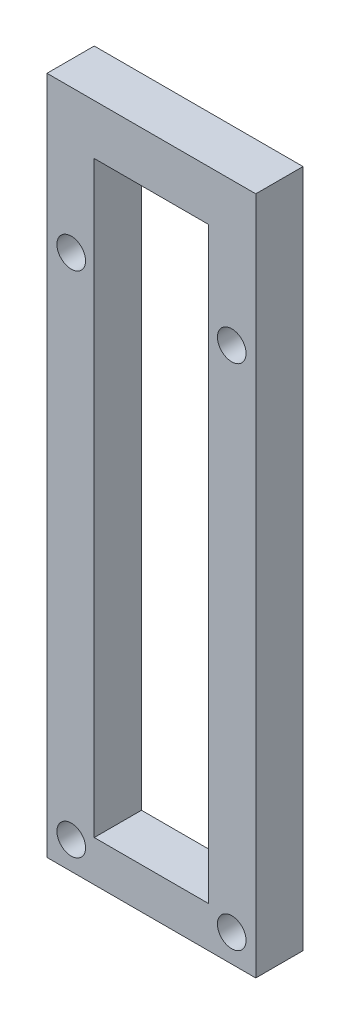
from build123d import *

# Parameters (mm, degrees)
BOSS_EXTRUDE1_DEPTH = 6.6
BOSS_EXTRUDE2_REACH = 24.56
SKETCH3_W           = 6.6
SKETCH3_H           = 7.003924561
SKETCH4_R           = 2
CUT_EXTRUDE1_DEPTH  = 15
SKETCH5_R           = 2
BOSS_EXTRUDE3_DEPTH = 6.69


with BuildPart() as part:
    # Sketch2 → Boss-Extrude1 (new body)
    with BuildSketch(Plane.XY):
        Polygon((0, 0), (0, 94.86), (-6.6, 94.86), (-6.6, 5.71), (-22.56, 5.71), (-22.56, 94.86), (-29.16, 94.86), (-29.16, 0), align=None)
    extrude(amount=BOSS_EXTRUDE1_DEPTH)

    # Sketch3 → Boss-Extrude2 (add, up to next)
    with BuildSketch(Plane(origin=(-22.56, 0, 0), x_dir=(0, 0, -1), z_dir=(1, 0, 0)), mode=Mode.PRIVATE) as boss_extrude2_sk1:
        with Locations((-3.3, 91.35803772)):
            Rectangle(SKETCH3_W, SKETCH3_H)
    boss_extrude2_tool1 = extrude(boss_extrude2_sk1.sketch, amount=BOSS_EXTRUDE2_REACH, mode=Mode.PRIVATE) - part.part
    add(boss_extrude2_tool1.solids().sort_by_distance((-22.56, 91.358038, 3.3))[0])

    # Sketch4 → Cut-Extrude1 (cut)
    with BuildSketch(Plane.XY.offset(6.6)):
        with Locations((-3.354353393, 47.428062363)):
            Circle(SKETCH4_R)
        with Locations((-25.771024386, 47.428062363)):
            Circle(SKETCH4_R)
        with Locations((-25.771024386, 3.86)):
            Circle(SKETCH4_R)
        with Locations((-3.354353393, 3.86)):
            Circle(SKETCH4_R)
        with Locations((-25.771024386, 74.86)):
            Circle(SKETCH4_R)
        with Locations((-3.354353393, 74.86)):
            Circle(SKETCH4_R)
    extrude(amount=-CUT_EXTRUDE1_DEPTH, mode=Mode.SUBTRACT)

    # Sketch5 → Boss-Extrude3 (add)
    with BuildSketch(Plane.XY.offset(6.6)):
        with Locations((-25.771024386, 47.428062363)):
            Circle(SKETCH5_R)
        with Locations((-3.354353393, 47.428062363)):
            Circle(SKETCH5_R)
    extrude(amount=-BOSS_EXTRUDE3_DEPTH)


solid = part.part
